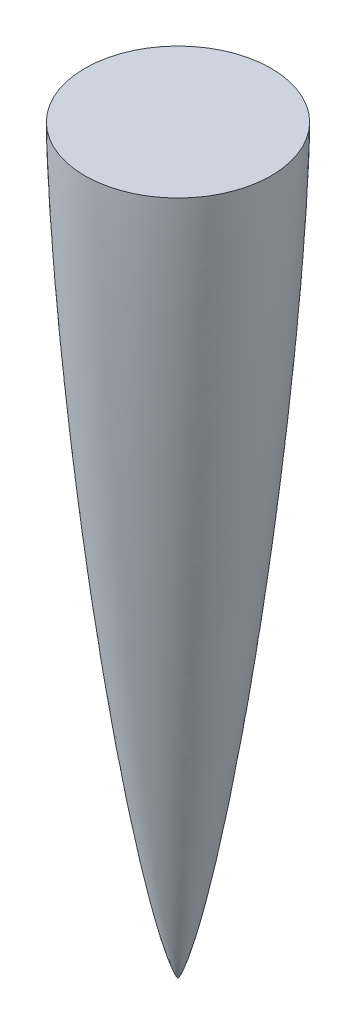
from build123d import *


with BuildPart() as part:
    # Sketch4 → Revolve2 (revolve)
    with BuildSketch(Plane.YZ):
        with BuildLine():
            Line((406.4, 51.054), (406.4, 0))
            Line((406.4, 0), (0, 0))
            add(Edge.make_bspline(
                [(0, 0), (0.00339952, 0.010554547), (0.012574325, 0.030559237), (0.039215965, 0.066417272), (0.081552945, 0.114014958), (0.134250383, 0.164137283), (0.210653795, 0.229893575), (0.323173514, 0.317220853), (0.49395501, 0.436130831), (0.761846071, 0.603352229), (1.192992221, 0.844869338), (1.916207715, 1.206827482), (3.195378804, 1.772560937), (5.546109059, 2.682603054), (9.85794582, 4.125923842), (17.131071969, 6.222010102), (29.988300984, 9.428108011), (47.942267832, 13.263697051), (70.026290739, 17.414351733), (95.102849328, 21.62207877), (120.237429542, 25.463489097), (145.416546594, 29.001091307), (170.630991544, 32.275566502), (195.87545716, 35.31016795), (221.145866801, 38.119805854), (246.439619917, 40.711123942), (268.590310157, 42.78825523), (287.589122501, 44.42897509), (303.429499136, 45.69887812), (316.106532446, 46.653927133), (328.788231387, 47.544923227), (341.474562226, 48.36750582), (352.579138015, 49.022257465), (362.100238046, 49.531847278), (370.036424678, 49.918228145), (376.386543421, 50.202341086), (382.429743923, 50.446446174), (388.165853466, 50.651719802), (392.95462623, 50.799444004), (396.795610591, 50.900443405), (399.996764141, 50.97079607), (402.237747974, 51.010959361), (404.158718369, 51.038154731), (405.43943342, 51.049398219), (406.079808332, 51.054), (406.4, 51.054)],
                knots=[0, 0, 0, 0, 0, 0.000107614, 0.000215229, 0.000430458, 0.000622201, 0.000813943, 0.001197429, 0.001816707, 0.002648259, 0.003888294, 0.006009041, 0.009690379, 0.01626604, 0.028430154, 0.050280206, 0.083390674, 0.145298946, 0.207206932, 0.269115279, 0.331023215, 0.392931344, 0.45483948, 0.516747575, 0.578655707, 0.640563775, 0.70247196, 0.733426023, 0.764380085, 0.795334113, 0.82628814, 0.857242198, 0.888196255, 0.903673281, 0.919150307, 0.934627332, 0.950104358, 0.962578268, 0.975052179, 0.981289134, 0.987526089, 0.993763045, 0.996881522, 1, 1, 1, 1, 1], degree=4))
        make_face()
    revolve(axis=Axis((0, -54.29126653, 0), (0, 1, 0)))


solid = part.part
